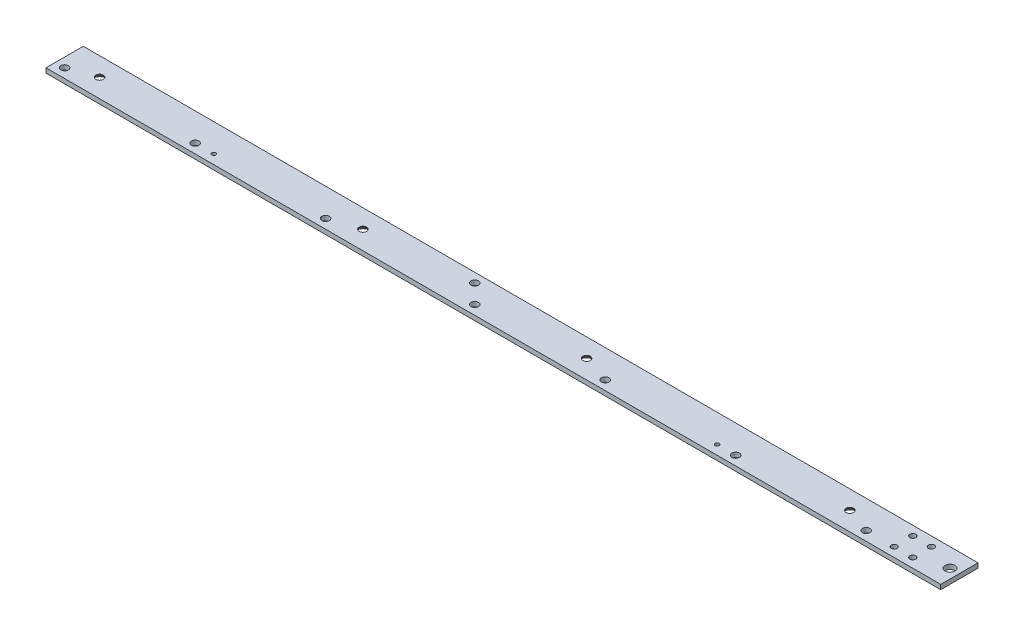
from build123d import *

# Parameters (mm, degrees)
SKETCH1_W                                    = 25.4
SKETCH1_H                                    = 3.175
BOSS_EXTRUDE1_DEPTH                          = 279.4
F_10_CLEARANCE_HOLE1_D                       = 5.1054
CSK_FOR_10_FLAT_HEAD_MACHINE_SCREW1_AT_COUNT = 2
CSK_FOR_10_FLAT_HEAD_MACHINE_SCREW1_AT_PITCH = 179.3875
F_6_32_TAPPED_HOLE1_D                        = 2.7051
F_10_CLEARANCE_HOLE2_D                       = 5.1054
SKETCH12_W                                   = 25.4
SKETCH12_H                                   = 3.175
BOSS_EXTRUDE2_DEPTH                          = 50.8
F_1_4_CLEARANCE_HOLE1_D                      = 6.7564
F_10_32_TAPPED_HOLE1_D                       = 4.0386


with BuildPart() as part:
    # Sketch1 → Boss-Extrude1 (new body, symmetric)
    with BuildSketch(Plane(origin=(0, 0, 0), x_dir=(0, 0, -1), z_dir=(1, 0, 0))):
        Rectangle(SKETCH1_W, SKETCH1_H)
    extrude(amount=BOSS_EXTRUDE1_DEPTH, both=True)

    # #10 Clearance Hole1 (through all)
    with Locations(Plane(origin=(0, 1.5875, 0), x_dir=(1, 0, 0), z_dir=(0, 1, 0))):
        with Locations((-273.05, -6.35), (-184.15, -6.35), (-95.25, -6.35)):
            f_10_clearance_hole1 = Hole(F_10_CLEARANCE_HOLE1_D / 2)

    # Sketch5 → CSK for #10 Flat Head Machine Screw1 (revolve, cut)
    with BuildSketch(Plane(origin=(-255.5875, -1.5875, 0), x_dir=(0, 0, -1), z_dir=(1, 0, 0))):
        Polygon((0, 0), (0, 3.175), (2.5527, 3.175), (2.5527, 2.688180894), (4.8895, 0), align=None)
    csk_for_10_flat_head_machine_screw1 = revolve(axis=Axis((-255.5875, -7.9375, 0), (0, 1, 0)), mode=Mode.SUBTRACT)

    # CSK for #10 Flat Head Machine Screw1 at: CSK for #10 Flat Head Machine Screw1 ×2
    with Locations(*[(i * CSK_FOR_10_FLAT_HEAD_MACHINE_SCREW1_AT_PITCH, 0, 0) for i in range(1, CSK_FOR_10_FLAT_HEAD_MACHINE_SCREW1_AT_COUNT)]):
        add(csk_for_10_flat_head_machine_screw1, mode=Mode.SUBTRACT)

    # #6-32 Tapped Hole1 (through all)
    with Locations(Plane(origin=(0, 1.5875, 0), x_dir=(1, 0, 0), z_dir=(0, 1, 0))):
        with Locations((-171.45, -6.35)):
            f_6_32_tapped_hole1 = Hole(F_6_32_TAPPED_HOLE1_D / 2)

    # Mirror1: #6-32 Tapped Hole1, #10 Clearance Hole1, CSK for #10 Flat Head Machine Screw1 across plane
    add(f_6_32_tapped_hole1.mirror(Plane(origin=(0, 0, 0), x_dir=(0, 0, 1), z_dir=(1, 0, 0))), mode=Mode.SUBTRACT)
    add(f_10_clearance_hole1.mirror(Plane(origin=(0, 0, 0), x_dir=(0, 0, 1), z_dir=(1, 0, 0))), mode=Mode.SUBTRACT)
    add(csk_for_10_flat_head_machine_screw1.mirror(Plane(origin=(0, 0, 0), x_dir=(0, 0, 1), z_dir=(1, 0, 0))), mode=Mode.SUBTRACT)

    # Mirror1 copy 1 sketch → Mirror1 copy 1 (revolve, cut)
    with BuildSketch(Plane(origin=(76.2, -1.5875, 0), x_dir=(0, 0, -1), z_dir=(-1, 0, 0))):
        Polygon((0, 0), (0, -3.175), (2.5527, -3.175), (2.5527, -2.688180894), (4.8895, 0), align=None)
    revolve(axis=Axis((76.2, -7.9375, 0), (0, -1, 0)), mode=Mode.SUBTRACT)

    # #10 Clearance Hole2 (through all)
    with Locations(Plane(origin=(0, 1.5875, 0), x_dir=(1, 0, 0), z_dir=(0, 1, 0))):
        with Locations((-6.35, 6.35), (6.35, -6.35)):
            Hole(F_10_CLEARANCE_HOLE2_D / 2)

    # Sketch12 → Boss-Extrude2 (add)
    with BuildSketch(Plane(origin=(279.4, 0, 0), x_dir=(0, 0, -1), z_dir=(1, 0, 0))):
        Rectangle(SKETCH12_W, SKETCH12_H)
    extrude(amount=BOSS_EXTRUDE2_DEPTH)

    # 1/4 Clearance Hole1 (through all)
    with Locations(Plane(origin=(0, 1.5875, 0), x_dir=(1, 0, 0), z_dir=(0, 1, 0))):
        with Locations((323.85, 0)):
            Hole(F_1_4_CLEARANCE_HOLE1_D / 2)

    # #10-32 Tapped Hole1 (through all)
    with Locations(Plane(origin=(0, 1.5875, 0), x_dir=(1, 0, 0), z_dir=(0, 1, 0))):
        with Locations((304.8, 6.35), (292.1, 6.35), (304.8, -6.35), (292.1, -6.35)):
            Hole(F_10_32_TAPPED_HOLE1_D / 2)


solid = part.part
